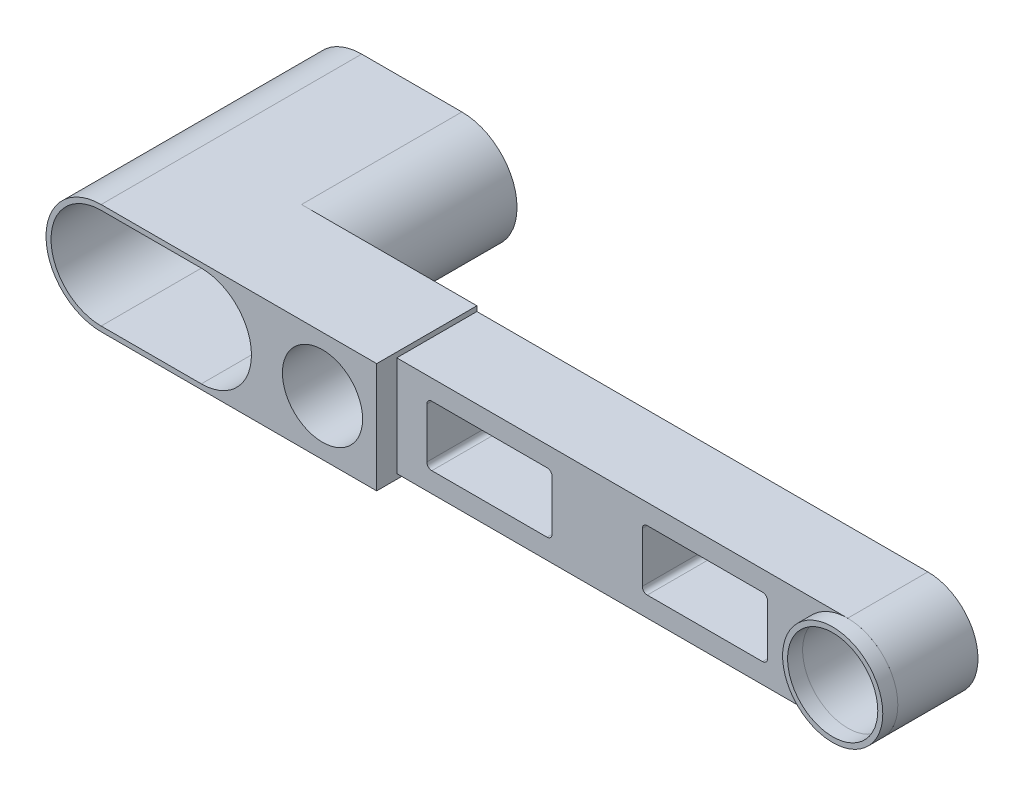
from build123d import *

# Parameters (mm, degrees)
SKETCH1_R             = 50
SKETCH1_W             = 100
SKETCH1_H             = 110
SKETCH1_W_2           = 230
SKETCH1_H_2           = 55
BOSS_EXTRUDE1_DEPTH   = 100
SKETCH2_W             = 160
SKETCH2_H             = 210
BOSS_EXTRUDE2_DEPTH   = 110
CUT_EXTRUDE1_DEPTH    = 260
CUT_EXTRUDE2_DEPTH    = 160
CUT_EXTRUDE3_DEPTH    = 100
BODY_MOVE_COPY1_ANGLE = 86
SKETCH15_R            = 40
CUT_EXTRUDE4_DEPTH    = 84
CUT_EXTRUDE5_DEPTH    = 20
BOSS_EXTRUDE3_DEPTH   = 15
BODY_MOVE_COPY6_ANGLE = 4
CUT_EXTRUDE6_DEPTH    = 270
SKETCH20_R            = 45
CUT_EXTRUDE7_DEPTH    = 70


with BuildPart() as part:
    # Sketch1 → Boss-Extrude1 (new body)
    with BuildSketch(Plane(origin=(0, 0, 0), x_dir=(0, 0, -1), z_dir=(1, 0, 0))):
        with BuildLine():
            Line((-50, 50), (-500, 50))
            ThreePointArc((-500, 50), (-464.644660941, 35.355339059), (-450, 0))
            ThreePointArc((-450, 0), (-464.644660941, -35.355339059), (-500, -50))
            Line((-500, -50), (-50, -50))
            Line((-50, -50), (-50, 50))
        make_face()
        with Locations((-500, 0)):
            Circle(SKETCH1_R)
        Rectangle(SKETCH1_W, SKETCH1_H)
        with Locations((165, -27.5)):
            Rectangle(SKETCH1_W_2, SKETCH1_H_2)
        with Locations((165, 27.5)):
            Rectangle(SKETCH1_W_2, SKETCH1_H_2)
    extrude(amount=BOSS_EXTRUDE1_DEPTH)

    # Sketch2 → Boss-Extrude2 (add)
    with BuildSketch(Plane(origin=(0, 55, 0), x_dir=(1, 0, 0), z_dir=(0, 1, 0))):
        with Locations((180, 175)):
            Rectangle(SKETCH2_W, SKETCH2_H)
    extrude(amount=-BOSS_EXTRUDE2_DEPTH)

    # Sketch3 → Cut-Extrude1 (cut)
    with BuildSketch(Plane(origin=(260, 0, 0), x_dir=(0, 0, -1), z_dir=(1, 0, 0))):
        with BuildLine():
            ThreePointArc((225, 55), (263.890872965, 38.890872965), (280, 0))
            Line((280, 0), (280, 55))
            Line((280, 55), (225, 55))
        make_face()
        with BuildLine():
            ThreePointArc((280, 0), (263.890872965, -38.890872965), (225, -55))
            Line((225, -55), (280, -55))
            Line((280, -55), (280, 0))
        make_face()
    extrude(amount=-CUT_EXTRUDE1_DEPTH, mode=Mode.SUBTRACT)

    # Sketch3_3 → Cut-Extrude2 (cut)
    with BuildSketch(Plane(origin=(260, 0, 0), x_dir=(0, 0, -1), z_dir=(1, 0, 0))):
        with BuildLine():
            Line((70, 55), (70, 2.89e-07))
            ThreePointArc((70, 2.89e-07), (86.109127186, 38.890873117), (125.00000014, 55))
            Line((125.00000014, 55), (70, 55))
        make_face()
        with BuildLine():
            Line((70, 2.89e-07), (70, -55))
            Line((70, -55), (125.000000101, -55))
            ThreePointArc((125.000000101, -55), (86.109126968, -38.890872899), (70, 2.89e-07))
        make_face()
    extrude(amount=-CUT_EXTRUDE2_DEPTH, mode=Mode.SUBTRACT)

    # Sketch12 → Cut-Extrude3 (cut)
    with BuildSketch(Plane.ZY):
        with BuildLine():
            Line((85, 30), (200, 30))
            ThreePointArc((200, 30), (203.535533906, 28.535533906), (205, 25))
            Line((205, 25), (205, -25))
            ThreePointArc((205, -25), (203.535533906, -28.535533906), (200, -30))
            Line((200, -30), (85, -30))
            ThreePointArc((85, -30), (81.464466094, -28.535533906), (80, -25))
            Line((80, -25), (80, 25))
            ThreePointArc((80, 25), (81.464466094, 28.535533906), (85, 30))
        make_face()
        with BuildLine():
            Line((415, -30), (300, -30))
            ThreePointArc((300, -30), (296.464466094, -28.535533906), (295, -25))
            Line((295, -25), (295, 25))
            ThreePointArc((295, 25), (296.464466094, 28.535533906), (300, 30))
            Line((300, 30), (415, 30))
            ThreePointArc((415, 30), (418.535533906, 28.535533906), (420, 25))
            Line((420, 25), (420, -25))
            ThreePointArc((420, -25), (418.535533906, -28.535533906), (415, -30))
        make_face()
    extrude(amount=-CUT_EXTRUDE3_DEPTH, mode=Mode.SUBTRACT)


with BuildPart() as part_1:
    # Body-Move_Copy1: moved
    add(part.part.rotate(Axis((130, 0, 135), (0, 1, 0)), BODY_MOVE_COPY1_ANGLE))

    # Sketch15 → Cut-Extrude4 (cut)
    with BuildSketch(Plane(origin=(-17.82995037, 0, 254.980169612), x_dir=(0.99756405, 0, 0.069756474), z_dir=(-0.069756474, 0, 0.99756405))):
        Circle(SKETCH15_R)
    extrude(amount=-CUT_EXTRUDE4_DEPTH, mode=Mode.SUBTRACT)


with BuildPart() as part_2:
    # Body-Move_Copy2: moved
    add(part_1.part.moved(Location((17.82995037, 0, -254.980169612))))

    # Sketch17 → Cut-Extrude5 (cut)
    with BuildSketch(Plane(origin=(0, 0, 0), x_dir=(0.99756405, 0, 0.069756474), z_dir=(-0.069756474, 0, 0.99756405))):
        with BuildLine():
            Line((54.100450489, 50), (54.100450489, -50))
            Line((54.100450489, -50), (504.100450489, -50))
            ThreePointArc((504.100450489, -50), (554.100450489, 0), (504.100450489, 50))
            Line((504.100450489, 50), (54.100450489, 50))
        make_face()
        with BuildLine():
            ThreePointArc((424.100450489, -25), (422.635984395, -28.535533906), (419.100450489, -30))
            Line((419.100450489, -30), (304.100450489, -30))
            ThreePointArc((304.100450489, -30), (300.564916583, -28.535533906), (299.100450489, -25))
            Line((299.100450489, -25), (299.100450489, 25))
            ThreePointArc((299.100450489, 25), (300.564916583, 28.535533906), (304.100450489, 30))
            Line((304.100450489, 30), (419.100450489, 30))
            ThreePointArc((419.100450489, 30), (422.635984395, 28.535533906), (424.100450489, 25))
            Line((424.100450489, 25), (424.100450489, -25))
        make_face(mode=Mode.SUBTRACT)
        with BuildLine():
            ThreePointArc((209.100450489, -25), (207.635984395, -28.535533906), (204.100450489, -30))
            Line((204.100450489, -30), (89.100450489, -30))
            ThreePointArc((89.100450489, -30), (85.564916583, -28.535533906), (84.100450489, -25))
            Line((84.100450489, -25), (84.100450489, 25))
            ThreePointArc((84.100450489, 25), (85.564916583, 28.535533906), (89.100450489, 30))
            Line((89.100450489, 30), (204.100450489, 30))
            ThreePointArc((204.100450489, 30), (207.635984395, 28.535533906), (209.100450489, 25))
            Line((209.100450489, 25), (209.100450489, -25))
        make_face(mode=Mode.SUBTRACT)
    extrude(amount=-CUT_EXTRUDE5_DEPTH, mode=Mode.SUBTRACT)


with BuildPart() as body_2:
    # Sketch18 → Boss-Extrude3 (new body)
    with BuildSketch(Plane(origin=(1.395129475, 0, -19.951281005), x_dir=(0.99756405, 0, 0.069756474), z_dir=(-0.069756474, 0, 0.99756405))):
        with BuildLine():
            ThreePointArc((554.100450489, 0), (539.455789548, 35.355339059), (504.100450489, 50))
            ThreePointArc((504.100450489, 50), (454.100450489, 0), (504.100450489, -50))
            ThreePointArc((504.100450489, -50), (539.455789548, -35.355339059), (554.100450489, 0))
        make_face()
    extrude(amount=BOSS_EXTRUDE3_DEPTH)


with BuildPart() as part_3:
    # Body-Move_Copy6: moved
    add(part_2.part.rotate(Axis((0, 0, 0), (0, 1, 0)), BODY_MOVE_COPY6_ANGLE))


with BuildPart() as body_2_1:
    # Body-Move_Copy6: moved
    add(body_2.part.rotate(Axis((0, 0, 0), (0, 1, 0)), BODY_MOVE_COPY6_ANGLE))


with BuildPart() as part_4:
    # Body-Move_Copy7: moved
    add(part_3.part.moved(Location((0, 0, -27.37))))

    # Sketch19 → Cut-Extrude6 (cut)
    with BuildSketch(Plane(origin=(0, 0, -287.37), x_dir=(-1, 0, 0), z_dir=(0, 0, -1))):
        with BuildLine():
            Line((120.899549511, -50), (220.899549511, -50))
            ThreePointArc((220.899549511, -50), (270.899549511, 0), (220.899549511, 50))
            Line((220.899549511, 50), (120.899549511, 50))
            ThreePointArc((120.899549511, 50), (70.899549511, 0), (120.899549511, -50))
        make_face()
    extrude(amount=-CUT_EXTRUDE6_DEPTH, mode=Mode.SUBTRACT)


with BuildPart() as body_2_2:
    # Body-Move_Copy7: moved
    add(body_2_1.part.moved(Location((0, 0, -27.37))))


with BuildPart() as cut_extrude7_tool:
    # Sketch20 → Cut-Extrude7 (new body)
    with BuildSketch(Plane.XY.offset(-32.37)):
        with Locations((504.100450489, 0)):
            Circle(SKETCH20_R)
    extrude(amount=-CUT_EXTRUDE7_DEPTH)


with BuildPart() as part_5:
    add(part_4.part)

    # Cut-Extrude7: cut by cut_extrude7_tool
    add(cut_extrude7_tool.part, mode=Mode.SUBTRACT)


with BuildPart() as body_2_3:
    add(body_2_2.part)

    # Cut-Extrude7: cut by cut_extrude7_tool
    add(cut_extrude7_tool.part, mode=Mode.SUBTRACT)


solid = Compound([part_5.part, body_2_3.part])
